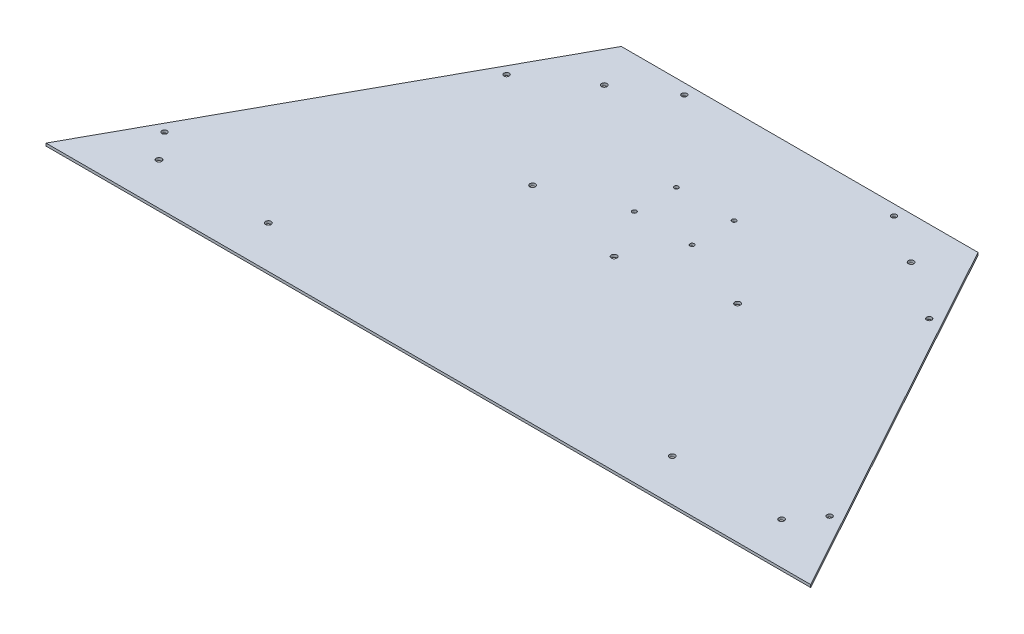
from build123d import *

# Parameters (mm, degrees)
BOSS_EXTRUDE1_DEPTH         = 3.175
F_1_4_0_25_DIAMETER_HOLE1_D = 6.35
F_1_4_CLEARANCE_HOLE1_D     = 6.7564
F_7_0_201_DIAMETER_HOLE1_D  = 5.1054


with BuildPart() as part:
    # Sketch1 → Boss-Extrude1 (new body)
    with BuildSketch(Plane(origin=(0, 0, 0), x_dir=(1, 0, 0), z_dir=(0, 1, 0))):
        Polygon((-462.534, 0), (-215.773, 449.26502653), (215.773, 449.26502653), (462.534, 0), align=None)
    extrude(amount=BOSS_EXTRUDE1_DEPTH)

    # 1/4 (0.25) Diameter Hole1 (through all)
    with Locations(Plane(origin=(0, 3.175, 0), x_dir=(1, 0, 0), z_dir=(0, 1, 0))):
        with Locations((-402.368285269, 83.160171278), (-255.632309055, 350.314795577), (-126.873, 436.56502653), (402.368285269, 83.160171278), (255.632309055, 350.314795577), (126.873, 436.56502653)):
            Hole(F_1_4_0_25_DIAMETER_HOLE1_D / 2)

    # 1/4 Clearance Hole1 (through all)
    with Locations(Plane(origin=(0, 3.175, 0), x_dir=(1, 0, 0), z_dir=(0, 1, 0))):
        with Locations((-376.682, 50.8), (-244.348, 50.8), (-123.952, 250.19), (-185.674, 398.526), (0, 224.79), (376.682, 50.8), (244.348, 50.8), (185.674, 398.526), (123.952, 250.19)):
            Hole(F_1_4_CLEARANCE_HOLE1_D / 2)

    # #7 (0.201) Diameter Hole1 (through all)
    with Locations(Plane(origin=(0, 3.175, 0), x_dir=(1, 0, 0), z_dir=(0, 1, 0))):
        with Locations((34.925, 334.96502653), (-34.925, 334.96502653), (-34.925, 284.16502653), (34.925, 284.16502653)):
            Hole(F_7_0_201_DIAMETER_HOLE1_D / 2)


solid = part.part
